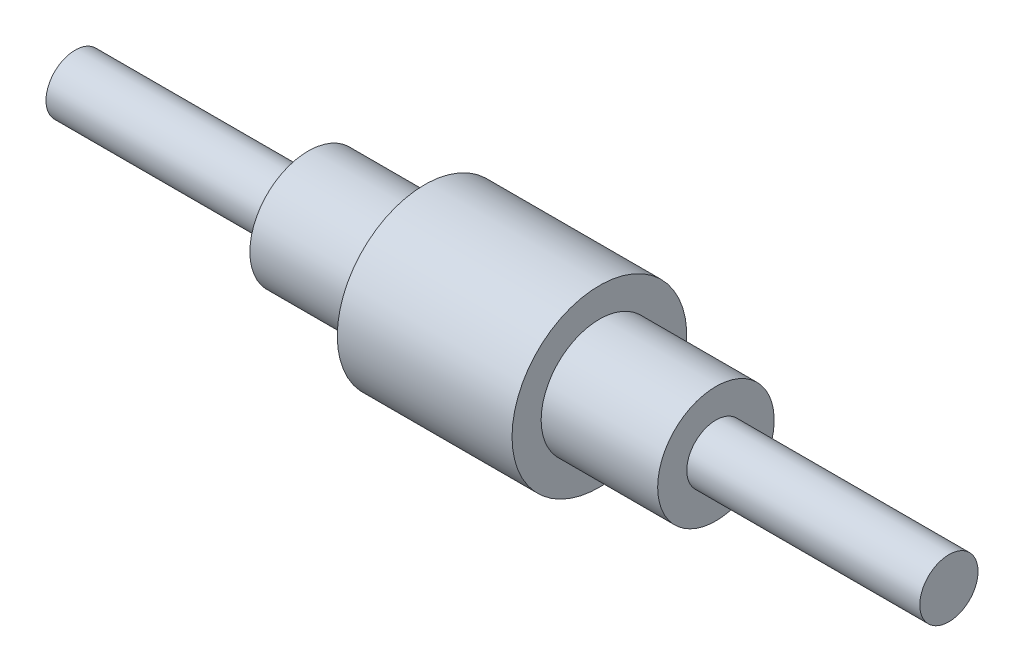
from build123d import *


with BuildPart() as part:
    # Sketch1 → Revolve1 (revolve)
    with BuildSketch(Plane.XY, mode=Mode.PRIVATE) as revolve1_sk:
        Polygon((0, 0), (0, -10), (80, -10), (80, -20), (120, -20), (120, -30), (180, -30), (180, -20), (220, -20), (220, -10), (300, -10), (300, 0), align=None)
    revolve(revolve1_sk.sketch.rotate(Axis((0, 0, 0), (1, 0, 0)), 270), axis=Axis((0, 0, 0), (1, 0, 0)))  # turned: the seam where the file's is


solid = part.part
